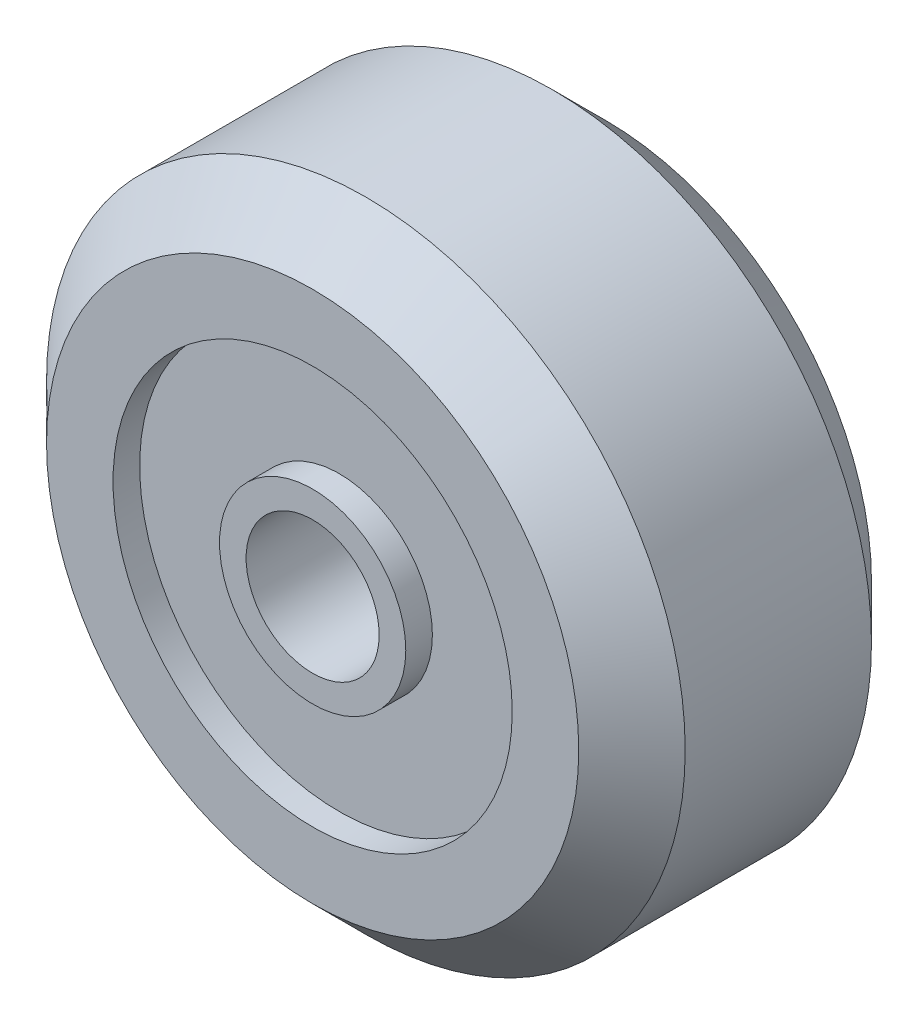
from build123d import *

# Parameters (mm, degrees)
SKETCH1_R           = 12
BOSS_EXTRUDE1_DEPTH = 11
CHAMFER1_SIZE       = 2
SKETCH2_R           = 2.5
CUT_EXTRUDE1_DEPTH  = 12
SKETCH3_R           = 7.5
SKETCH3_R_2         = 3.5
CUT_EXTRUDE2_DEPTH  = 1
SKETCH4_R           = 7.5
SKETCH4_R_2         = 3.5
CUT_EXTRUDE3_DEPTH  = 1


with BuildPart() as part:
    # Sketch1 → Boss-Extrude1 (new body)
    with BuildSketch(Plane.XY):
        Circle(SKETCH1_R)
    extrude(amount=BOSS_EXTRUDE1_DEPTH)

    # Chamfer1
    chamfer1_edges = [part.edges().sort_by_distance(p)[0] for p in [
        (-12, 0, 0),
        (-12, 0, 11),
    ]]
    chamfer(chamfer1_edges, length=CHAMFER1_SIZE)

    # Sketch2 → Cut-Extrude1 (cut, through all)
    with BuildSketch(Plane.XY.offset(11)):
        Circle(SKETCH2_R)
    extrude(amount=-CUT_EXTRUDE1_DEPTH, mode=Mode.SUBTRACT)

    # Sketch3 → Cut-Extrude2 (cut)
    with BuildSketch(Plane.XY.offset(11)):
        Circle(SKETCH3_R)
        Circle(SKETCH3_R_2, mode=Mode.SUBTRACT)
    extrude(amount=-CUT_EXTRUDE2_DEPTH, mode=Mode.SUBTRACT)

    # Sketch4 → Cut-Extrude3 (cut)
    with BuildSketch(Plane(origin=(0, 0, 0), x_dir=(-1, 0, 0), z_dir=(0, 0, -1))):
        Circle(SKETCH4_R)
        Circle(SKETCH4_R_2, mode=Mode.SUBTRACT)
    extrude(amount=-CUT_EXTRUDE3_DEPTH, mode=Mode.SUBTRACT)


solid = part.part
